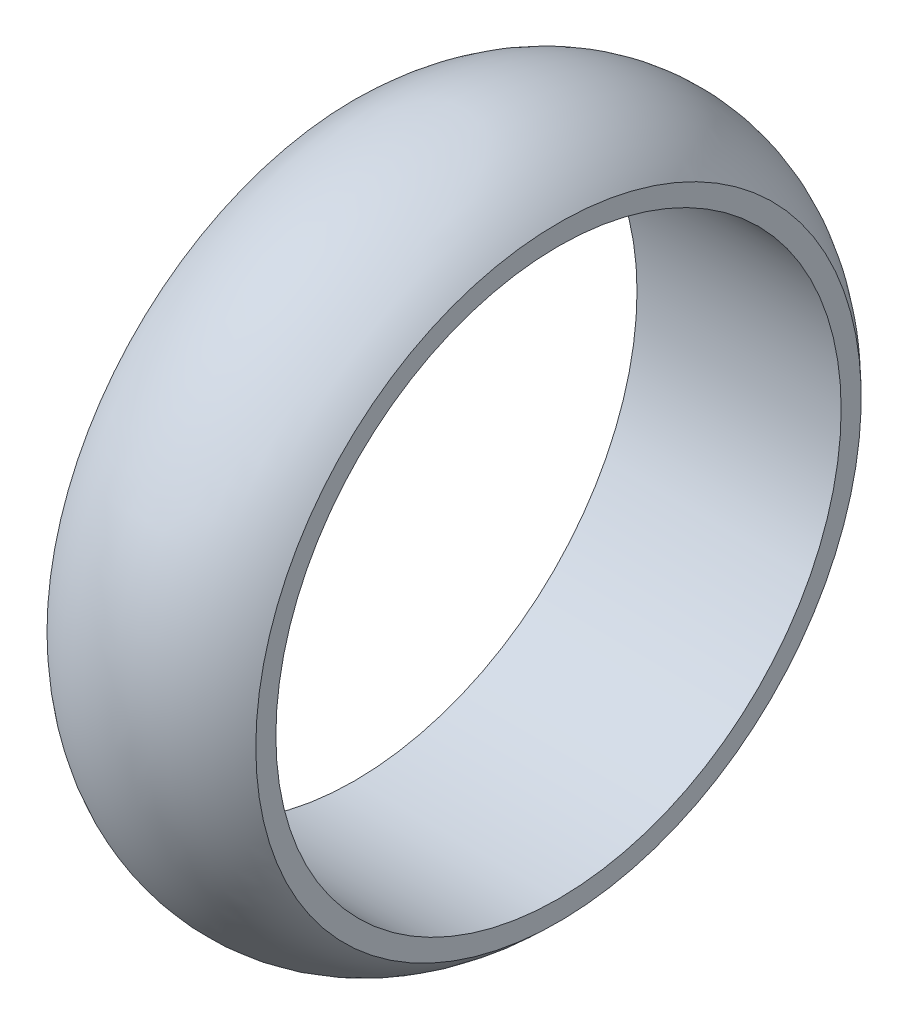
from build123d import *


with BuildPart() as part:
    # Croquis1 → Revolución1 (revolve)
    with BuildSketch(Plane.XY):
        with BuildLine():
            Line((-82.55, 228.6), (-82.55, 248.6))
            ThreePointArc((-82.55, 248.6), (0.78126118, 280.920500567), (82.55, 244.829127658))
            Line((82.55, 244.829127658), (82.55, 228.6))
            Line((82.55, 228.6), (-82.55, 228.6))
        make_face()
    revolve(axis=Axis((-74.208090301, 0, 0), (1, 0, 0)))


solid = part.part
